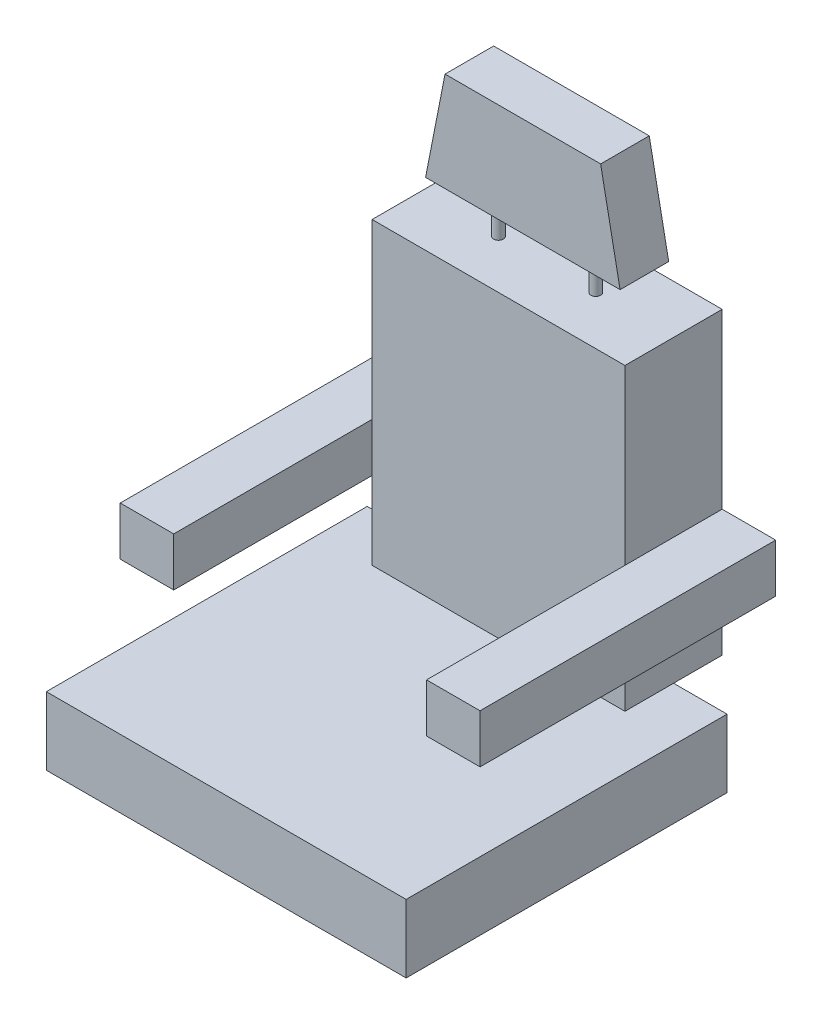
from build123d import *

# Parameters (mm, degrees)
SKETCH1_W           = 469.9
SKETCH1_H           = 419.1
BOSS_EXTRUDE1_DEPTH = 88.9
SKETCH2_W           = 330.2
SKETCH2_H           = 391.16
BOSS_EXTRUDE2_DEPTH = 63.5
SKETCH3_W           = 386.08
SKETCH3_H           = 63.5
BOSS_EXTRUDE3_DEPTH = 69.85
SKETCH4_R           = 6.35
BOSS_EXTRUDE4_DEPTH = 50.8
SKETCH5_W           = 254
SKETCH5_H           = 63.5
BOSS_EXTRUDE5_DEPTH = 129.54
CUT_EXTRUDE1_DEPTH  = 129.54


with BuildPart() as part:
    # Sketch1 → Boss-Extrude1 (new body)
    with BuildSketch(Plane(origin=(0, 0, 0), x_dir=(1, 0, 0), z_dir=(0, 1, 0))):
        Rectangle(SKETCH1_W, SKETCH1_H)
    extrude(amount=BOSS_EXTRUDE1_DEPTH)


with BuildPart() as body_2:
    # Sketch2 → Boss-Extrude2 (new body, symmetric)
    with BuildSketch(Plane.XY.offset(-209.55)):
        with Locations((0, 284.48)):
            Rectangle(SKETCH2_W, SKETCH2_H)
    extrude(amount=BOSS_EXTRUDE2_DEPTH, both=True)

    # Sketch3 → Boss-Extrude3 (add)
    with BuildSketch(Plane(origin=(165.1, 0, 0), x_dir=(0, 0, -1), z_dir=(1, 0, 0))):
        with Locations((80.01, 222.25)):
            Rectangle(SKETCH3_W, SKETCH3_H)
    boss_extrude3 = extrude(amount=BOSS_EXTRUDE3_DEPTH)

    # Mirror1: Boss-Extrude3 across plane
    add(boss_extrude3.mirror(Plane(origin=(0, 0, 0), x_dir=(0, 0, 1), z_dir=(1, 0, 0))))

    # Sketch4 → Boss-Extrude4 (add)
    with BuildSketch(Plane(origin=(0, 480.06, 0), x_dir=(1, 0, 0), z_dir=(0, 1, 0))):
        with Locations((-63.5, 209.55)):
            Circle(SKETCH4_R)
        with Locations((63.5, 209.55)):
            Circle(SKETCH4_R)
    extrude(amount=BOSS_EXTRUDE4_DEPTH)

    # Sketch5 → Boss-Extrude5 (add)
    with BuildSketch(Plane(origin=(0, 530.86, 0), x_dir=(1, 0, 0), z_dir=(0, 1, 0))):
        with Locations((0, 209.55)):
            Rectangle(SKETCH5_W, SKETCH5_H)
    extrude(amount=BOSS_EXTRUDE5_DEPTH)

    # Sketch6 → Cut-Extrude1 (cut)
    with BuildSketch(Plane.XY.offset(-177.8)):
        Polygon((101.6, 660.4), (127, 530.86), (127, 660.4), align=None)
        Polygon((-127, 660.4), (-127, 530.86), (-101.6, 660.4), align=None)
    extrude(amount=-CUT_EXTRUDE1_DEPTH, mode=Mode.SUBTRACT)


solid = Compound([part.part, body_2.part])
